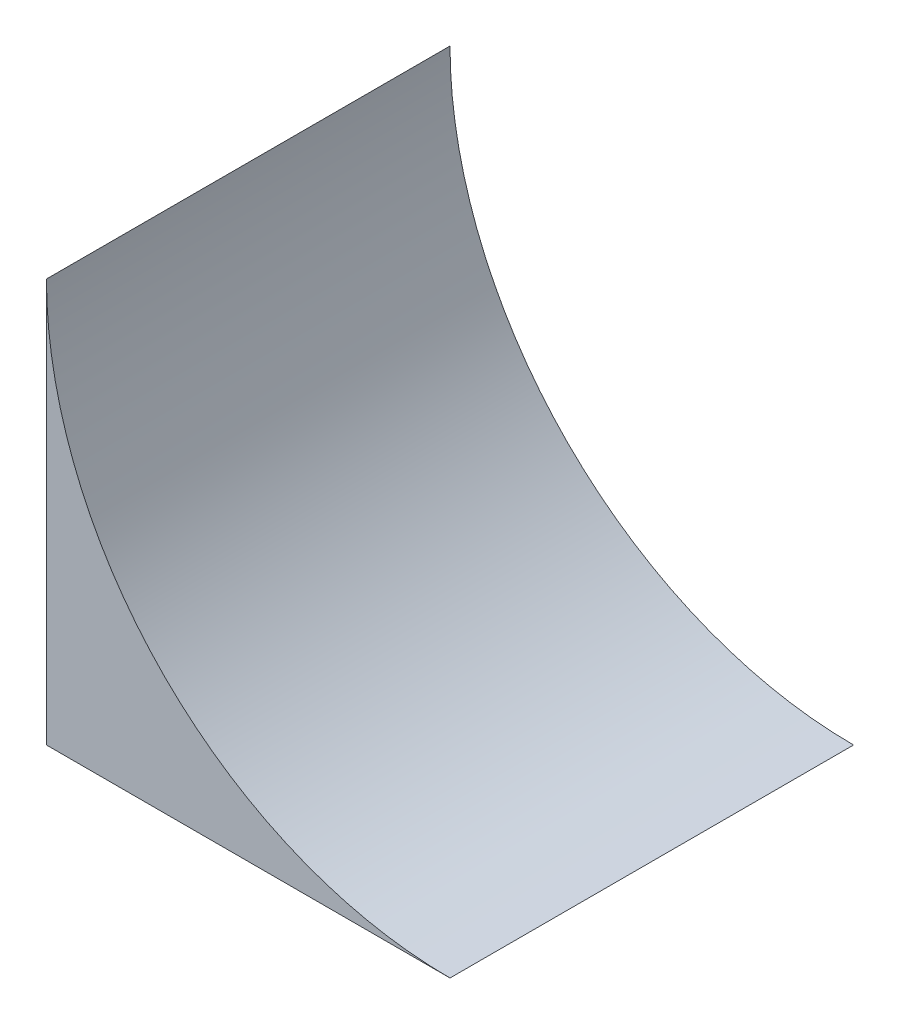
from build123d import *

# Parameters (mm, degrees)
SALIENTE_EXTRUIR1_DEPTH = 6


with BuildPart() as part:
    # Croquis1 → Saliente-Extruir1 (new body)
    with BuildSketch(Plane.XY):
        with BuildLine():
            Line((0, 0), (6, 0))
            ThreePointArc((6, 0), (1.757359313, 1.757359313), (0, 6))
            Line((0, 6), (0, 0))
        make_face()
    extrude(amount=SALIENTE_EXTRUIR1_DEPTH)


solid = part.part
